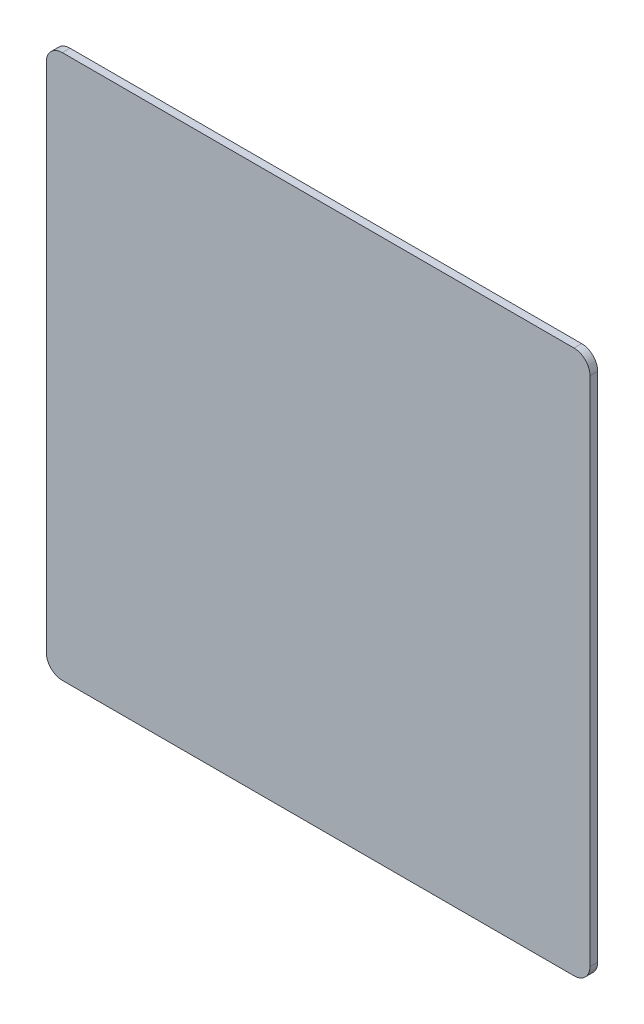
from build123d import *

# Parameters (mm, degrees)
BOSS_EXTRUDE1_DEPTH = 0.12


with BuildPart() as part:
    # Sketch1 → Boss-Extrude1 (new body)
    with BuildSketch(Plane.XY.offset(0.12)):
        with BuildLine():
            Line((8.25, 0.25), (8.25, 8.25))
            ThreePointArc((8.25, 8.25), (8.176776695, 8.426776695), (8, 8.5))
            Line((8, 8.5), (0, 8.5))
            ThreePointArc((0, 8.5), (-0.176776695, 8.426776695), (-0.25, 8.25))
            Line((-0.25, 8.25), (-0.25, 0.25))
            ThreePointArc((-0.25, 0.25), (-0.176776695, 0.073223305), (0, 0))
            Line((0, 0), (8, 0))
            ThreePointArc((8, 0), (8.176776695, 0.073223305), (8.25, 0.25))
        make_face()
    extrude(amount=-BOSS_EXTRUDE1_DEPTH)


solid = part.part
